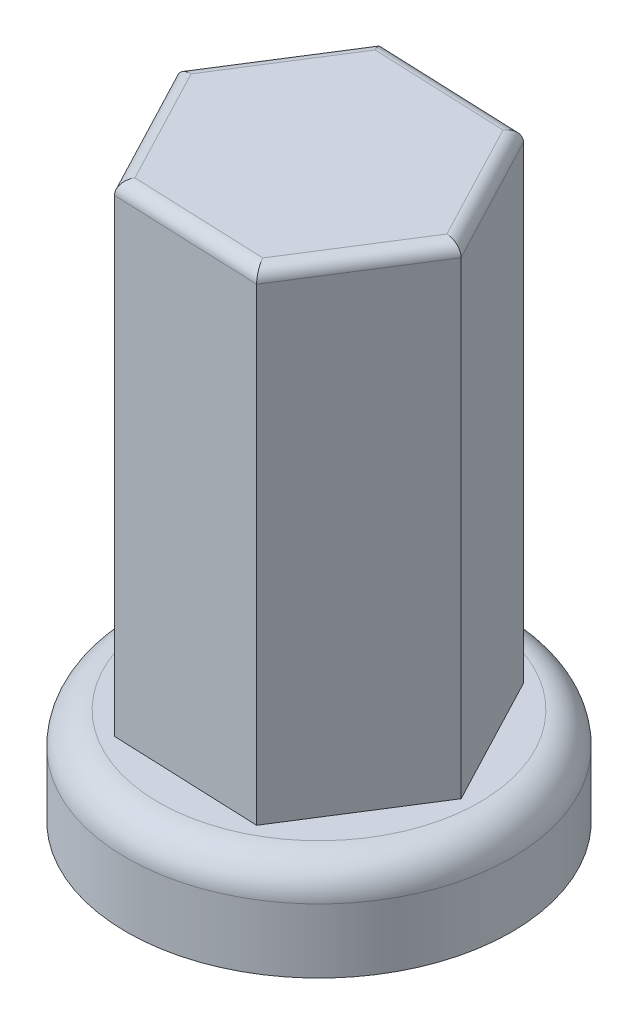
from build123d import *

# Parameters (mm, degrees)
SKETCH1_R           = 7.62
BOSS_EXTRUDE1_DEPTH = 3.81
BOSS_EXTRUDE2_DEPTH = 19.05
FILLET1_R           = 1.27
FILLET2_R           = 0.508
SKETCH3_R           = 4.699
CUT_EXTRUDE1_DEPTH  = 19.05


with BuildPart() as part:
    # Sketch1 → Boss-Extrude1 (new body)
    with BuildSketch(Plane(origin=(0, 0, 0), x_dir=(1, 0, 0), z_dir=(0, 1, 0))):
        Circle(SKETCH1_R)
    extrude(amount=BOSS_EXTRUDE1_DEPTH)

    # Sketch2 → Boss-Extrude2 (add)
    with BuildSketch(Plane(origin=(0, 3.81, 0), x_dir=(1, 0, 0), z_dir=(0, 1, 0))):
        Polygon((5.861093772, -0.236882109), (3.13569281, 4.957415046), (-2.725400962, 5.194297155), (-5.861093772, 0.236882109), (-3.13569281, -4.957415046), (2.725400962, -5.194297155), align=None)
    extrude(amount=BOSS_EXTRUDE2_DEPTH)

    # Fillet1
    fillet1_edges = [part.edges().sort_by_distance(p)[0] for p in [
        (-7.62, 3.81, 0),
    ]]
    fillet(fillet1_edges, radius=FILLET1_R)

    # Fillet2
    fillet2_edges = [part.edges().sort_by_distance(p)[0] for p in [
        (4.293247367, 22.86, 2.715589632),
        (4.498393291, 22.86, -2.360266469),
        (0.205145924, 22.86, -5.0758561),
        (-4.293247367, 22.86, -2.715589632),
        (-4.498393291, 22.86, 2.360266469),
        (-0.205145924, 22.86, 5.0758561),
    ]]
    fillet(fillet2_edges, radius=FILLET2_R)

    # Sketch3 → Cut-Extrude1 (cut)
    with BuildSketch(Plane.XZ):
        Circle(SKETCH3_R)
    extrude(amount=-CUT_EXTRUDE1_DEPTH, mode=Mode.SUBTRACT)


solid = part.part
